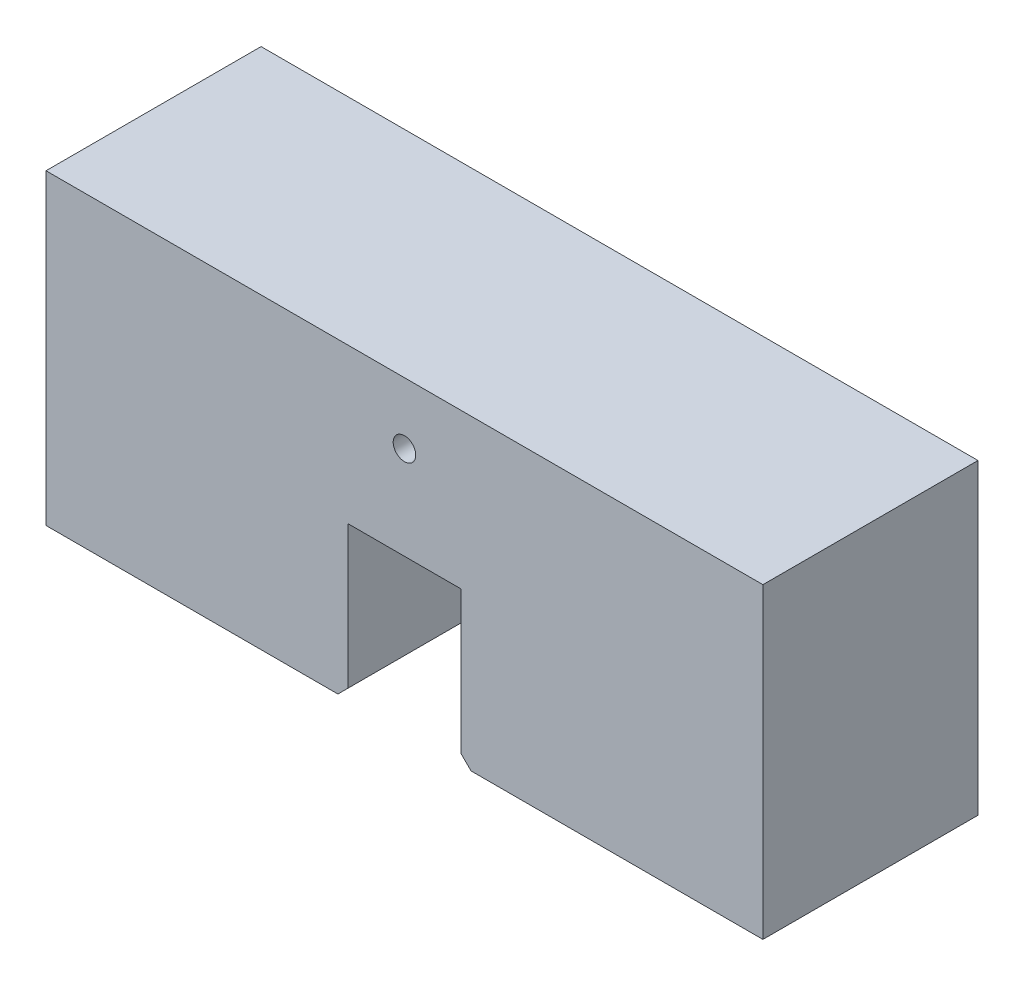
from build123d import *

# Parameters (mm, degrees)
BOSS_EXTRUDE1_DEPTH     = 105
SKETCH2_R               = 11
CUT_EXTRUDE1_DEPTH      = 106
CUT_EXTRUDE1_DEPTH_BACK = 106


with BuildPart() as part:
    # Sketch1 → Boss-Extrude1 (new body, symmetric)
    with BuildSketch(Plane.XY):
        Polygon((350, 232.421392473), (-350, 232.421392473), (-350, -67.578607527), (-65, -67.578607527), (-55, -57.578607527), (-55, 81.421392473), (55, 81.421392473), (55, -57.578607527), (65, -67.578607527), (350, -67.578607527), align=None)
    extrude(amount=BOSS_EXTRUDE1_DEPTH, both=True)

    # Sketch2 → Cut-Extrude1 (cut, two sides)
    with BuildSketch(Plane.XY) as cut_extrude1_sk:
        with Locations((0, 172.421392473)):
            Circle(SKETCH2_R)
    extrude(amount=CUT_EXTRUDE1_DEPTH, mode=Mode.SUBTRACT)
    extrude(cut_extrude1_sk.sketch, amount=-CUT_EXTRUDE1_DEPTH_BACK, mode=Mode.SUBTRACT)


solid = part.part
